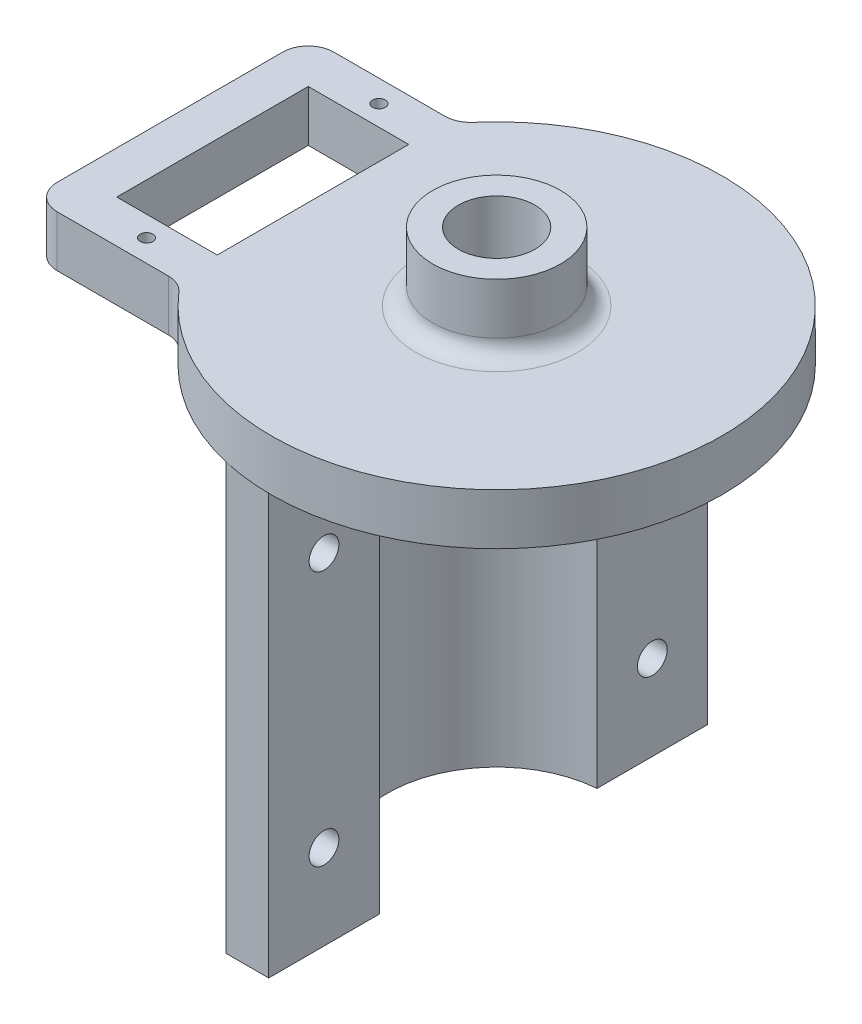
from build123d import *

# Parameters (mm, degrees)
BOSS_EXTRUDE4_DEPTH = 50
SKETCH7_R           = 1.75
CUT_EXTRUDE1_DEPTH  = 17.825
SKETCH8_R           = 0.75
SKETCH8_W           = 11.8
SKETCH8_H           = 22.5
BOSS_EXTRUDE5_DEPTH = 6
SKETCH9_R           = 7.5
BOSS_EXTRUDE6_DEPTH = 8
FILLET1_R           = 2
SKETCH10_R          = 4.5
CUT_EXTRUDE2_DEPTH  = 65


with BuildPart() as part:
    # Sketch6 → Boss-Extrude4 (new body)
    with BuildSketch(Plane.XZ):
        with BuildLine():
            Line((-1, 25.784833184), (-1, 12.785954208))
            ThreePointArc((-1, 12.785954208), (-12.825, 0), (-1, -12.785954208))
            Line((-1, -12.785954208), (-1, -25.784833184))
            Line((-1, -25.784833184), (-6, -25.784833184))
            Line((-6, -25.784833184), (-6, -16.784833184))
            ThreePointArc((-6, -16.784833184), (-17.825, 0), (-6, 16.784833184))
            Line((-6, 16.784833184), (-6, 25.784833184))
            Line((-6, 25.784833184), (-1, 25.784833184))
        make_face()
    extrude(amount=BOSS_EXTRUDE4_DEPTH)

    # Sketch7 → Cut-Extrude1 (cut, through all)
    with BuildSketch(Plane(origin=(-1, 0, 0), x_dir=(0, 0, -1), z_dir=(1, 0, 0))):
        with Locations((-19.285393696, -10)):
            Circle(SKETCH7_R)
        with Locations((-19.285393696, -40)):
            Circle(SKETCH7_R)
        with Locations((19.285393696, -40)):
            Circle(SKETCH7_R)
        with Locations((19.285393696, -10)):
            Circle(SKETCH7_R)
    extrude(amount=-CUT_EXTRUDE1_DEPTH, mode=Mode.SUBTRACT)

    # Sketch8 → Boss-Extrude5 (add)
    with BuildSketch(Plane(origin=(0, 0, 0), x_dir=(1, 0, 0), z_dir=(0, 1, 0))):
        with BuildLine():
            Line((-35.384131785, -16.25), (-22.318992281, -16.25))
            ThreePointArc((-22.318992281, -16.25), (-21.069616181, -16.522536094), (-20.047240136, -17.290627093))
            ThreePointArc((-20.047240136, -17.290627093), (26.473715688, 0), (-20.047240136, 17.290627093))
            ThreePointArc((-20.047240136, 17.290627093), (-21.069616181, 16.522536094), (-22.318992281, 16.25))
            Line((-22.318992281, 16.25), (-35.384131785, 16.25))
            ThreePointArc((-35.384131785, 16.25), (-37.505452129, 15.371320344), (-38.384131785, 13.25))
            Line((-38.384131785, 13.25), (-38.384131785, -13.25))
            ThreePointArc((-38.384131785, -13.25), (-37.505452129, -15.371320344), (-35.384131785, -16.25))
        make_face()
        with Locations((-27.484131785, 13.65)):
            Circle(SKETCH8_R, mode=Mode.SUBTRACT)
        with Locations((-27.484131785, -13.65)):
            Circle(SKETCH8_R, mode=Mode.SUBTRACT)
        with Locations((-27.484131785, 0)):
            Rectangle(SKETCH8_W, SKETCH8_H, mode=Mode.SUBTRACT)
    extrude(amount=BOSS_EXTRUDE5_DEPTH)

    # Sketch9 → Boss-Extrude6 (add)
    with BuildSketch(Plane(origin=(0, 6, 0), x_dir=(1, 0, 0), z_dir=(0, 1, 0))):
        Circle(SKETCH9_R)
    extrude(amount=BOSS_EXTRUDE6_DEPTH)

    # Fillet1
    fillet1_edges = [part.edges().sort_by_distance(p)[0] for p in [
        (-7.5, 6, 0),
    ]]
    fillet(fillet1_edges, radius=FILLET1_R)

    # Sketch10 → Cut-Extrude2 (cut, through all)
    with BuildSketch(Plane(origin=(0, 14, 0), x_dir=(1, 0, 0), z_dir=(0, 1, 0))):
        Circle(SKETCH10_R)
    extrude(amount=-CUT_EXTRUDE2_DEPTH, mode=Mode.SUBTRACT)


solid = part.part
